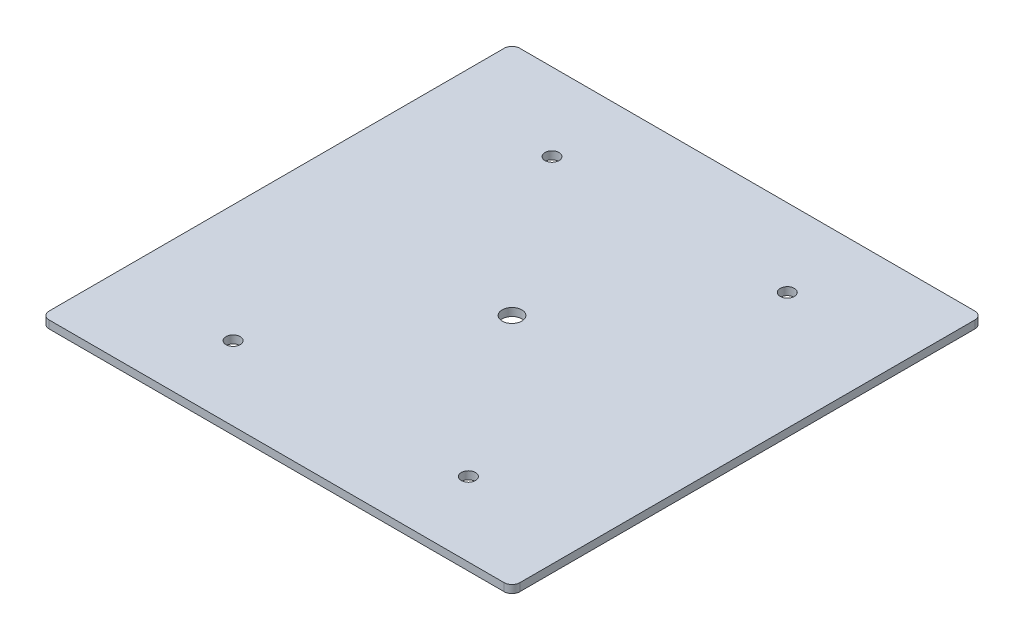
from build123d import *

# Parameters (mm, degrees)
SKETCH1_R           = 1.4224
BOSS_EXTRUDE1_DEPTH = 2.54
SKETCH2_R           = 2.286
SKETCH2_R_2         = 3.175
CUT_EXTRUDE1_DEPTH  = 3.54


with BuildPart() as part:
    # Sketch1 → Boss-Extrude1 (new body)
    with BuildSketch(Plane(origin=(0, 0, 0), x_dir=(1, 0, 0), z_dir=(0, 1, 0))):
        with BuildLine():
            Line((-73.66, 76.2), (73.66, 76.2))
            ThreePointArc((73.66, 76.2), (75.456051224, 75.456051224), (76.2, 73.66))
            Line((76.2, 73.66), (76.2, -73.66))
            ThreePointArc((76.2, -73.66), (75.456051224, -75.456051224), (73.66, -76.2))
            Line((73.66, -76.2), (-73.66, -76.2))
            ThreePointArc((-73.66, -76.2), (-75.456051224, -75.456051224), (-76.2, -73.66))
            Line((-76.2, -73.66), (-76.2, 73.66))
            ThreePointArc((-76.2, 73.66), (-75.456051224, 75.456051224), (-73.66, 76.2))
        make_face()
        Circle(SKETCH1_R, mode=Mode.SUBTRACT)
    extrude(amount=BOSS_EXTRUDE1_DEPTH)

    # Sketch2 → Cut-Extrude1 (cut, through all)
    with BuildSketch(Plane(origin=(0, 2.54, 0), x_dir=(1, 0, 0), z_dir=(0, 1, 0))):
        with Locations((-38.1, 51.05145896)):
            Circle(SKETCH2_R)
        with Locations((38.1, 51.05145896)):
            Circle(SKETCH2_R)
        with Locations((38.1, -52.221692976)):
            Circle(SKETCH2_R)
        with Locations((-38.1, -52.221692976)):
            Circle(SKETCH2_R)
        Circle(SKETCH2_R_2)
    extrude(amount=-CUT_EXTRUDE1_DEPTH, mode=Mode.SUBTRACT)


solid = part.part
